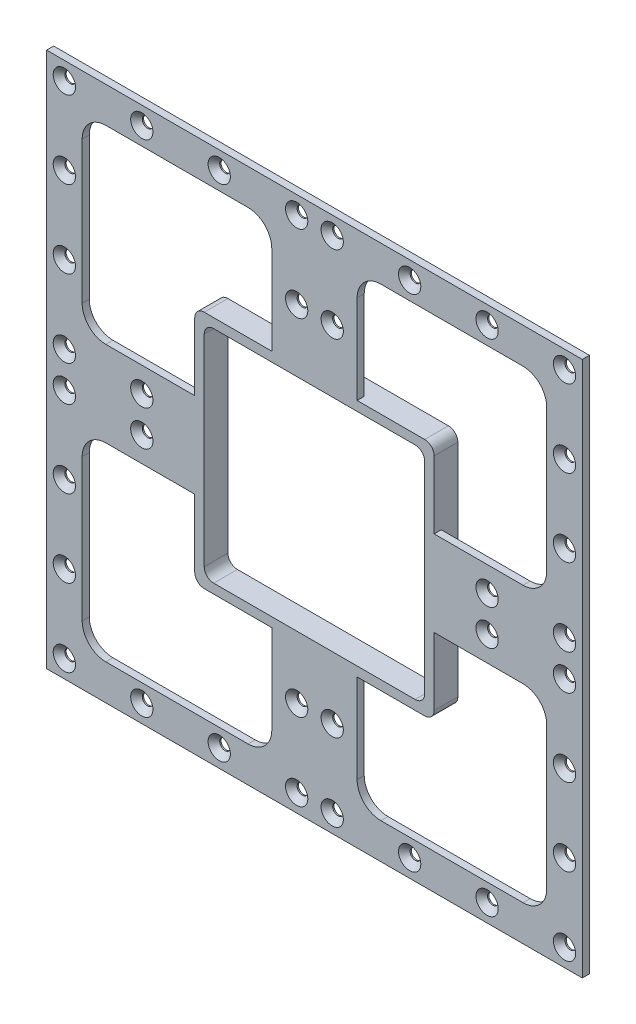
from build123d import *

# Parameters (mm, degrees)
SKETCH1_W              = 226
SKETCH1_H              = 226
BOSS_EXTRUDE1_DEPTH    = 3
SKETCH2_W              = 80
SKETCH2_H              = 80
CUT_EXTRUDE2_DEPTH     = 4
FILLET1_R              = 10
LPATTERN2_COUNT        = 2
LPATTERN2_PITCH        = 116
LPATTERN2_COUNT_DIR2   = 2
LPATTERN2_PITCH_DIR2   = 116
FILLET1_OF_LPATTERN2_R = 10
LPATTERN8_COUNT        = 4
LPATTERN8_PITCH        = 32.666666667
LPATTERN8_COUNT_DIR2   = 4
LPATTERN8_PITCH_DIR2   = 32.666666667
CUT_EXTRUDE3_REACH     = 5
SKETCH14_W             = 101
SKETCH14_H             = 101
SKETCH15_W             = 101
SKETCH15_H             = 101
SKETCH15_W_2           = 93
SKETCH15_H_2           = 93
BOSS_EXTRUDE2_DEPTH    = 10
FILLET2_R              = 4


with BuildPart() as part:
    # Sketch1 → Boss-Extrude1 (new body)
    with BuildSketch(Plane.XY):
        Rectangle(SKETCH1_W, SKETCH1_H)
    extrude(amount=BOSS_EXTRUDE1_DEPTH)

    # Sketch2 → Cut-Extrude2 (cut, through all)
    with BuildSketch(Plane.XY):
        with Locations((-58, 58)):
            Rectangle(SKETCH2_W, SKETCH2_H)
    cut_extrude2 = extrude(amount=CUT_EXTRUDE2_DEPTH, mode=Mode.SUBTRACT)

    # Fillet1
    fillet1_edges = [part.edges().sort_by_distance(p)[0] for p in [
        (-18, 18, 1.5),
        (-18, 98, 1.5),
        (-98, 98, 1.5),
        (-98, 18, 1.5),
    ]]
    fillet(fillet1_edges, radius=FILLET1_R)

    # LPattern2: Cut-Extrude2 2 × 2
    with Locations(*[(j * LPATTERN2_PITCH_DIR2, -i * LPATTERN2_PITCH, 0) for i in range(LPATTERN2_COUNT) for j in range(LPATTERN2_COUNT_DIR2) if (i, j) != (0, 0)]):
        add(cut_extrude2, mode=Mode.SUBTRACT)

    # Fillet1 of LPattern2
    fillet1_of_lpattern2_edges = [part.edges().sort_by_distance(p)[0] for p in [
        (98, 18, 1.5),
        (98, 98, 1.5),
        (18, 98, 1.5),
        (18, 18, 1.5),
        (-18, -98, 1.5),
        (-18, -18, 1.5),
        (-98, -18, 1.5),
        (-98, -98, 1.5),
        (98, -98, 1.5),
        (98, -18, 1.5),
        (18, -18, 1.5),
        (18, -98, 1.5),
    ]]
    fillet(fillet1_of_lpattern2_edges, radius=FILLET1_OF_LPATTERN2_R)

    # Sketch12 → CSK for M4 Flat Head Machine Screw4 (revolve, cut)
    with BuildSketch(Plane(origin=(-105.5, 105.5, 3), x_dir=(0, -1, 0), z_dir=(1, 0, 0))):
        Polygon((0, 0), (0, 3), (2.25, 3), (2.25, 2.45), (4.7, 0), align=None)
    csk_for_m4_flat_head_machine_screw4 = revolve(axis=Axis((-105.5, 105.5, 9.35), (0, 0, -1)), mode=Mode.SUBTRACT)

    # LPattern8: CSK for M4 Flat Head Machine Screw4 4 × 4, 4 skipped
    with Locations(*[(i * LPATTERN8_PITCH, -j * LPATTERN8_PITCH_DIR2, 0) for i in range(LPATTERN8_COUNT) for j in range(LPATTERN8_COUNT_DIR2) if (i, j) not in ((0, 0), (1, 1), (1, 2), (2, 1), (2, 2))]):
        add(csk_for_m4_flat_head_machine_screw4, mode=Mode.SUBTRACT)

    # Mirror1: CSK for M4 Flat Head Machine Screw4 across plane
    add(csk_for_m4_flat_head_machine_screw4.mirror(Plane(origin=(0, 0, 0), x_dir=(0, 0, 1), z_dir=(1, 0, 0))), mode=Mode.SUBTRACT)

    # Mirror1 copy 1 sketch → Mirror1 copy 1 (revolve, cut)
    with BuildSketch(Plane(origin=(105.5, 72.833333333, 3), x_dir=(0, -1, 0), z_dir=(-1, 0, 0))):
        Polygon((0, 0), (0, -3), (2.25, -3), (2.25, -2.45), (4.7, 0), align=None)
    revolve(axis=Axis((105.5, 72.833333333, 9.35), (0, 0, 1)), mode=Mode.SUBTRACT)

    # Mirror1 copy 2 sketch → Mirror1 copy 2 (revolve, cut)
    with BuildSketch(Plane(origin=(105.5, 40.166666667, 3), x_dir=(0, -1, 0), z_dir=(-1, 0, 0))):
        Polygon((0, 0), (0, -3), (2.25, -3), (2.25, -2.45), (4.7, 0), align=None)
    revolve(axis=Axis((105.5, 40.166666667, 9.35), (0, 0, 1)), mode=Mode.SUBTRACT)

    # Mirror1 copy 3 sketch → Mirror1 copy 3 (revolve, cut)
    with BuildSketch(Plane(origin=(105.5, 7.5, 3), x_dir=(0, -1, 0), z_dir=(-1, 0, 0))):
        Polygon((0, 0), (0, -3), (2.25, -3), (2.25, -2.45), (4.7, 0), align=None)
    revolve(axis=Axis((105.5, 7.5, 9.35), (0, 0, 1)), mode=Mode.SUBTRACT)

    # Mirror1 copy 4 sketch → Mirror1 copy 4 (revolve, cut)
    with BuildSketch(Plane(origin=(72.833333333, 105.5, 3), x_dir=(0, -1, 0), z_dir=(-1, 0, 0))):
        Polygon((0, 0), (0, -3), (2.25, -3), (2.25, -2.45), (4.7, 0), align=None)
    revolve(axis=Axis((72.833333333, 105.5, 9.35), (0, 0, 1)), mode=Mode.SUBTRACT)

    # Mirror1 copy 5 sketch → Mirror1 copy 5 (revolve, cut)
    with BuildSketch(Plane(origin=(72.833333333, 7.5, 3), x_dir=(0, -1, 0), z_dir=(-1, 0, 0))):
        Polygon((0, 0), (0, -3), (2.25, -3), (2.25, -2.45), (4.7, 0), align=None)
    revolve(axis=Axis((72.833333333, 7.5, 9.35), (0, 0, 1)), mode=Mode.SUBTRACT)

    # Mirror1 copy 6 sketch → Mirror1 copy 6 (revolve, cut)
    with BuildSketch(Plane(origin=(40.166666667, 105.5, 3), x_dir=(0, -1, 0), z_dir=(-1, 0, 0))):
        Polygon((0, 0), (0, -3), (2.25, -3), (2.25, -2.45), (4.7, 0), align=None)
    revolve(axis=Axis((40.166666667, 105.5, 9.35), (0, 0, 1)), mode=Mode.SUBTRACT)

    # Mirror1 copy 7 sketch → Mirror1 copy 7 (revolve, cut)
    with BuildSketch(Plane(origin=(40.166666667, 7.5, 3), x_dir=(0, -1, 0), z_dir=(-1, 0, 0))):
        Polygon((0, 0), (0, -3), (2.25, -3), (2.25, -2.45), (4.7, 0), align=None)
    revolve(axis=Axis((40.166666667, 7.5, 9.35), (0, 0, 1)), mode=Mode.SUBTRACT)

    # Mirror1 copy 8 sketch → Mirror1 copy 8 (revolve, cut)
    with BuildSketch(Plane(origin=(7.5, 105.5, 3), x_dir=(0, -1, 0), z_dir=(-1, 0, 0))):
        Polygon((0, 0), (0, -3), (2.25, -3), (2.25, -2.45), (4.7, 0), align=None)
    revolve(axis=Axis((7.5, 105.5, 9.35), (0, 0, 1)), mode=Mode.SUBTRACT)

    # Mirror1 copy 9 sketch → Mirror1 copy 9 (revolve, cut)
    with BuildSketch(Plane(origin=(7.5, 72.833333333, 3), x_dir=(0, -1, 0), z_dir=(-1, 0, 0))):
        Polygon((0, 0), (0, -3), (2.25, -3), (2.25, -2.45), (4.7, 0), align=None)
    revolve(axis=Axis((7.5, 72.833333333, 9.35), (0, 0, 1)), mode=Mode.SUBTRACT)

    # Mirror1 copy 10 sketch → Mirror1 copy 10 (revolve, cut)
    with BuildSketch(Plane(origin=(7.5, 40.166666667, 3), x_dir=(0, -1, 0), z_dir=(-1, 0, 0))):
        Polygon((0, 0), (0, -3), (2.25, -3), (2.25, -2.45), (4.7, 0), align=None)
    revolve(axis=Axis((7.5, 40.166666667, 9.35), (0, 0, 1)), mode=Mode.SUBTRACT)

    # Mirror1 copy 11 sketch → Mirror1 copy 11 (revolve, cut)
    with BuildSketch(Plane(origin=(7.5, 7.5, 3), x_dir=(0, -1, 0), z_dir=(-1, 0, 0))):
        Polygon((0, 0), (0, -3), (2.25, -3), (2.25, -2.45), (4.7, 0), align=None)
    revolve(axis=Axis((7.5, 7.5, 9.35), (0, 0, 1)), mode=Mode.SUBTRACT)

    # Mirror1 at the second plane: CSK for M4 Flat Head Machine Screw4 across plane
    add(csk_for_m4_flat_head_machine_screw4.mirror(Plane.ZX), mode=Mode.SUBTRACT)

    # Mirror1 at the second plane copy 1 sketc → Mirror1 at the second plane copy 1 (revolve, cut)
    with BuildSketch(Plane(origin=(-105.5, -72.833333333, 3), x_dir=(0, 1, 0), z_dir=(1, 0, 0))):
        Polygon((0, 0), (0, -3), (2.25, -3), (2.25, -2.45), (4.7, 0), align=None)
    revolve(axis=Axis((-105.5, -72.833333333, 9.35), (0, 0, 1)), mode=Mode.SUBTRACT)

    # Mirror1 at the second plane copy 2 sketc → Mirror1 at the second plane copy 2 (revolve, cut)
    with BuildSketch(Plane(origin=(-105.5, -40.166666667, 3), x_dir=(0, 1, 0), z_dir=(1, 0, 0))):
        Polygon((0, 0), (0, -3), (2.25, -3), (2.25, -2.45), (4.7, 0), align=None)
    revolve(axis=Axis((-105.5, -40.166666667, 9.35), (0, 0, 1)), mode=Mode.SUBTRACT)

    # Mirror1 at the second plane copy 3 sketc → Mirror1 at the second plane copy 3 (revolve, cut)
    with BuildSketch(Plane(origin=(-105.5, -7.5, 3), x_dir=(0, 1, 0), z_dir=(1, 0, 0))):
        Polygon((0, 0), (0, -3), (2.25, -3), (2.25, -2.45), (4.7, 0), align=None)
    revolve(axis=Axis((-105.5, -7.5, 9.35), (0, 0, 1)), mode=Mode.SUBTRACT)

    # Mirror1 at the second plane copy 4 sketc → Mirror1 at the second plane copy 4 (revolve, cut)
    with BuildSketch(Plane(origin=(-72.833333333, -105.5, 3), x_dir=(0, 1, 0), z_dir=(1, 0, 0))):
        Polygon((0, 0), (0, -3), (2.25, -3), (2.25, -2.45), (4.7, 0), align=None)
    revolve(axis=Axis((-72.833333333, -105.5, 9.35), (0, 0, 1)), mode=Mode.SUBTRACT)

    # Mirror1 at the second plane copy 5 sketc → Mirror1 at the second plane copy 5 (revolve, cut)
    with BuildSketch(Plane(origin=(-72.833333333, -7.5, 3), x_dir=(0, 1, 0), z_dir=(1, 0, 0))):
        Polygon((0, 0), (0, -3), (2.25, -3), (2.25, -2.45), (4.7, 0), align=None)
    revolve(axis=Axis((-72.833333333, -7.5, 9.35), (0, 0, 1)), mode=Mode.SUBTRACT)

    # Mirror1 at the second plane copy 6 sketc → Mirror1 at the second plane copy 6 (revolve, cut)
    with BuildSketch(Plane(origin=(-40.166666667, -105.5, 3), x_dir=(0, 1, 0), z_dir=(1, 0, 0))):
        Polygon((0, 0), (0, -3), (2.25, -3), (2.25, -2.45), (4.7, 0), align=None)
    revolve(axis=Axis((-40.166666667, -105.5, 9.35), (0, 0, 1)), mode=Mode.SUBTRACT)

    # Mirror1 at the second plane copy 7 sketc → Mirror1 at the second plane copy 7 (revolve, cut)
    with BuildSketch(Plane(origin=(-40.166666667, -7.5, 3), x_dir=(0, 1, 0), z_dir=(1, 0, 0))):
        Polygon((0, 0), (0, -3), (2.25, -3), (2.25, -2.45), (4.7, 0), align=None)
    revolve(axis=Axis((-40.166666667, -7.5, 9.35), (0, 0, 1)), mode=Mode.SUBTRACT)

    # Mirror1 at the second plane copy 8 sketc → Mirror1 at the second plane copy 8 (revolve, cut)
    with BuildSketch(Plane(origin=(-7.5, -105.5, 3), x_dir=(0, 1, 0), z_dir=(1, 0, 0))):
        Polygon((0, 0), (0, -3), (2.25, -3), (2.25, -2.45), (4.7, 0), align=None)
    revolve(axis=Axis((-7.5, -105.5, 9.35), (0, 0, 1)), mode=Mode.SUBTRACT)

    # Mirror1 at the second plane copy 9 sketc → Mirror1 at the second plane copy 9 (revolve, cut)
    with BuildSketch(Plane(origin=(-7.5, -72.833333333, 3), x_dir=(0, 1, 0), z_dir=(1, 0, 0))):
        Polygon((0, 0), (0, -3), (2.25, -3), (2.25, -2.45), (4.7, 0), align=None)
    revolve(axis=Axis((-7.5, -72.833333333, 9.35), (0, 0, 1)), mode=Mode.SUBTRACT)

    # Mirror1 at the second plane copy 10 sket → Mirror1 at the second plane copy 10 (revolve, cut)
    with BuildSketch(Plane(origin=(-7.5, -40.166666667, 3), x_dir=(0, 1, 0), z_dir=(1, 0, 0))):
        Polygon((0, 0), (0, -3), (2.25, -3), (2.25, -2.45), (4.7, 0), align=None)
    revolve(axis=Axis((-7.5, -40.166666667, 9.35), (0, 0, 1)), mode=Mode.SUBTRACT)

    # Mirror1 at the second plane copy 11 sket → Mirror1 at the second plane copy 11 (revolve, cut)
    with BuildSketch(Plane(origin=(-7.5, -7.5, 3), x_dir=(0, 1, 0), z_dir=(1, 0, 0))):
        Polygon((0, 0), (0, -3), (2.25, -3), (2.25, -2.45), (4.7, 0), align=None)
    revolve(axis=Axis((-7.5, -7.5, 9.35), (0, 0, 1)), mode=Mode.SUBTRACT)

    # Mirror1 at the second plane copy 12 sket → Mirror1 at the second plane copy 12 (revolve, cut)
    with BuildSketch(Plane(origin=(105.5, -105.5, 3), x_dir=(0, 1, 0), z_dir=(-1, 0, 0))):
        Polygon((0, 0), (0, 3), (2.25, 3), (2.25, 2.45), (4.7, 0), align=None)
    revolve(axis=Axis((105.5, -105.5, 9.35), (0, 0, -1)), mode=Mode.SUBTRACT)

    # Mirror1 at the second plane copy 13 sket → Mirror1 at the second plane copy 13 (revolve, cut)
    with BuildSketch(Plane(origin=(105.5, -72.833333333, 3), x_dir=(0, 1, 0), z_dir=(-1, 0, 0))):
        Polygon((0, 0), (0, 3), (2.25, 3), (2.25, 2.45), (4.7, 0), align=None)
    revolve(axis=Axis((105.5, -72.833333333, 9.35), (0, 0, -1)), mode=Mode.SUBTRACT)

    # Mirror1 at the second plane copy 14 sket → Mirror1 at the second plane copy 14 (revolve, cut)
    with BuildSketch(Plane(origin=(105.5, -40.166666667, 3), x_dir=(0, 1, 0), z_dir=(-1, 0, 0))):
        Polygon((0, 0), (0, 3), (2.25, 3), (2.25, 2.45), (4.7, 0), align=None)
    revolve(axis=Axis((105.5, -40.166666667, 9.35), (0, 0, -1)), mode=Mode.SUBTRACT)

    # Mirror1 at the second plane copy 15 sket → Mirror1 at the second plane copy 15 (revolve, cut)
    with BuildSketch(Plane(origin=(105.5, -7.5, 3), x_dir=(0, 1, 0), z_dir=(-1, 0, 0))):
        Polygon((0, 0), (0, 3), (2.25, 3), (2.25, 2.45), (4.7, 0), align=None)
    revolve(axis=Axis((105.5, -7.5, 9.35), (0, 0, -1)), mode=Mode.SUBTRACT)

    # Mirror1 at the second plane copy 16 sket → Mirror1 at the second plane copy 16 (revolve, cut)
    with BuildSketch(Plane(origin=(72.833333333, -105.5, 3), x_dir=(0, 1, 0), z_dir=(-1, 0, 0))):
        Polygon((0, 0), (0, 3), (2.25, 3), (2.25, 2.45), (4.7, 0), align=None)
    revolve(axis=Axis((72.833333333, -105.5, 9.35), (0, 0, -1)), mode=Mode.SUBTRACT)

    # Mirror1 at the second plane copy 17 sket → Mirror1 at the second plane copy 17 (revolve, cut)
    with BuildSketch(Plane(origin=(72.833333333, -7.5, 3), x_dir=(0, 1, 0), z_dir=(-1, 0, 0))):
        Polygon((0, 0), (0, 3), (2.25, 3), (2.25, 2.45), (4.7, 0), align=None)
    revolve(axis=Axis((72.833333333, -7.5, 9.35), (0, 0, -1)), mode=Mode.SUBTRACT)

    # Mirror1 at the second plane copy 18 sket → Mirror1 at the second plane copy 18 (revolve, cut)
    with BuildSketch(Plane(origin=(40.166666667, -105.5, 3), x_dir=(0, 1, 0), z_dir=(-1, 0, 0))):
        Polygon((0, 0), (0, 3), (2.25, 3), (2.25, 2.45), (4.7, 0), align=None)
    revolve(axis=Axis((40.166666667, -105.5, 9.35), (0, 0, -1)), mode=Mode.SUBTRACT)

    # Mirror1 at the second plane copy 19 sket → Mirror1 at the second plane copy 19 (revolve, cut)
    with BuildSketch(Plane(origin=(40.166666667, -7.5, 3), x_dir=(0, 1, 0), z_dir=(-1, 0, 0))):
        Polygon((0, 0), (0, 3), (2.25, 3), (2.25, 2.45), (4.7, 0), align=None)
    revolve(axis=Axis((40.166666667, -7.5, 9.35), (0, 0, -1)), mode=Mode.SUBTRACT)

    # Mirror1 at the second plane copy 20 sket → Mirror1 at the second plane copy 20 (revolve, cut)
    with BuildSketch(Plane(origin=(7.5, -105.5, 3), x_dir=(0, 1, 0), z_dir=(-1, 0, 0))):
        Polygon((0, 0), (0, 3), (2.25, 3), (2.25, 2.45), (4.7, 0), align=None)
    revolve(axis=Axis((7.5, -105.5, 9.35), (0, 0, -1)), mode=Mode.SUBTRACT)

    # Mirror1 at the second plane copy 21 sket → Mirror1 at the second plane copy 21 (revolve, cut)
    with BuildSketch(Plane(origin=(7.5, -72.833333333, 3), x_dir=(0, 1, 0), z_dir=(-1, 0, 0))):
        Polygon((0, 0), (0, 3), (2.25, 3), (2.25, 2.45), (4.7, 0), align=None)
    revolve(axis=Axis((7.5, -72.833333333, 9.35), (0, 0, -1)), mode=Mode.SUBTRACT)

    # Mirror1 at the second plane copy 22 sket → Mirror1 at the second plane copy 22 (revolve, cut)
    with BuildSketch(Plane(origin=(7.5, -40.166666667, 3), x_dir=(0, 1, 0), z_dir=(-1, 0, 0))):
        Polygon((0, 0), (0, 3), (2.25, 3), (2.25, 2.45), (4.7, 0), align=None)
    revolve(axis=Axis((7.5, -40.166666667, 9.35), (0, 0, -1)), mode=Mode.SUBTRACT)

    # Mirror1 at the second plane copy 23 sket → Mirror1 at the second plane copy 23 (revolve, cut)
    with BuildSketch(Plane(origin=(7.5, -7.5, 3), x_dir=(0, 1, 0), z_dir=(-1, 0, 0))):
        Polygon((0, 0), (0, 3), (2.25, 3), (2.25, 2.45), (4.7, 0), align=None)
    revolve(axis=Axis((7.5, -7.5, 9.35), (0, 0, -1)), mode=Mode.SUBTRACT)

    # Sketch14 → Cut-Extrude3 (cut, up to next)
    with BuildSketch(Plane.XY.offset(3), mode=Mode.PRIVATE) as cut_extrude3_sk1:
        Rectangle(SKETCH14_W, SKETCH14_H)
    cut_extrude3_tool1 = extrude(cut_extrude3_sk1.sketch, amount=-CUT_EXTRUDE3_REACH, mode=Mode.PRIVATE) & part.part
    add(cut_extrude3_tool1.solids().sort_by_distance((0, 0, 3))[0], mode=Mode.SUBTRACT)

    # Sketch15 → Boss-Extrude2 (add)
    with BuildSketch(Plane.XY.offset(3)):
        Rectangle(SKETCH15_W, SKETCH15_H)
        Rectangle(SKETCH15_W_2, SKETCH15_H_2, mode=Mode.SUBTRACT)
    extrude(amount=-BOSS_EXTRUDE2_DEPTH)

    # Fillet2
    fillet2_edges = [part.edges().sort_by_distance(p)[0] for p in [
        (50.5, 50.5, -2),
        (50.5, -50.5, -2),
        (-50.5, -50.5, -2),
        (-50.5, 50.5, -2),
        (46.5, -46.5, -2),
        (-46.5, -46.5, -2),
        (-46.5, 46.5, -2),
        (46.5, 46.5, -2),
    ]]
    fillet(fillet2_edges, radius=FILLET2_R)


solid = part.part
